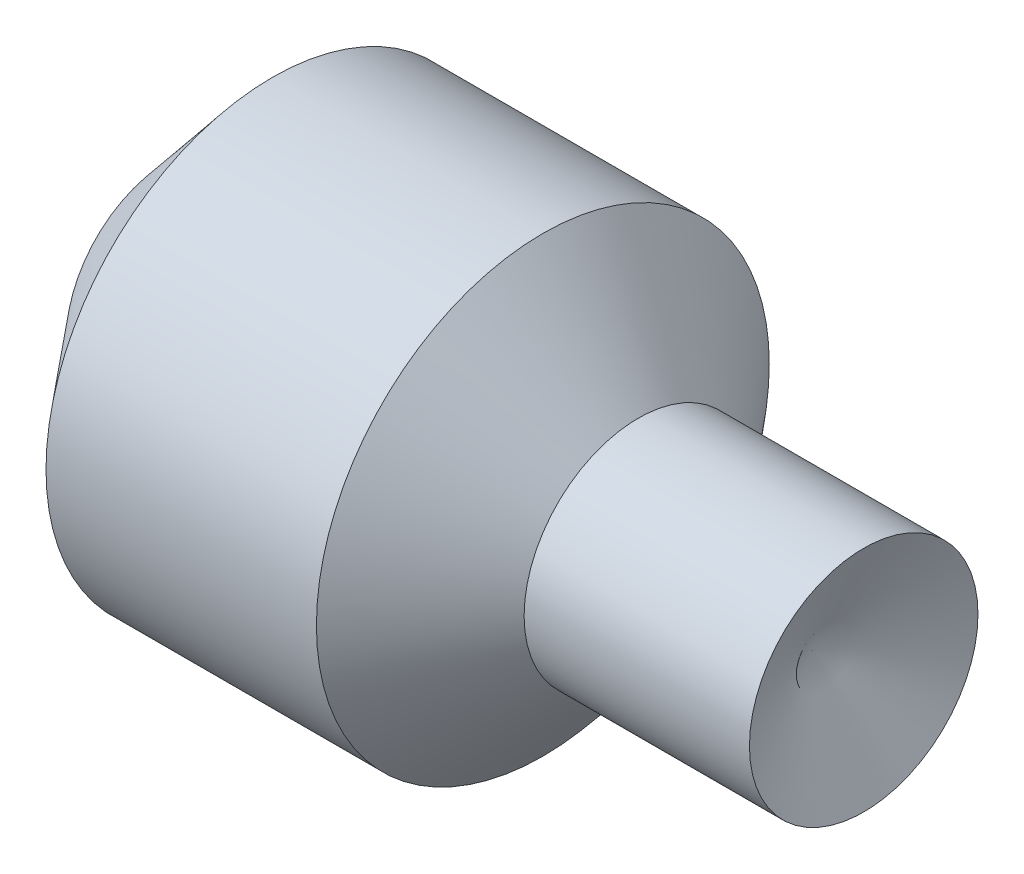
from build123d import *


with BuildPart() as part:
    # Croquis1 → Revolución1 (revolve)
    with BuildSketch(Plane.XY):
        Polygon((6.632713902, 40.004478225), (-43.040252409, 40.004478225), (-64.102627652, 64.726186359), (-96.212652303, 64.726186359), (-123.710187225, 64.726186359), (-146.240425516, 37.760861791), (-156.62986127, 14.813188168), (-145.224640248, 14.813188168), (-4.773363078, 14.813188168), align=None)
    revolve(axis=Axis((-145.224640248, 14.813188168, 0), (1, 0, 0)))


solid = part.part
